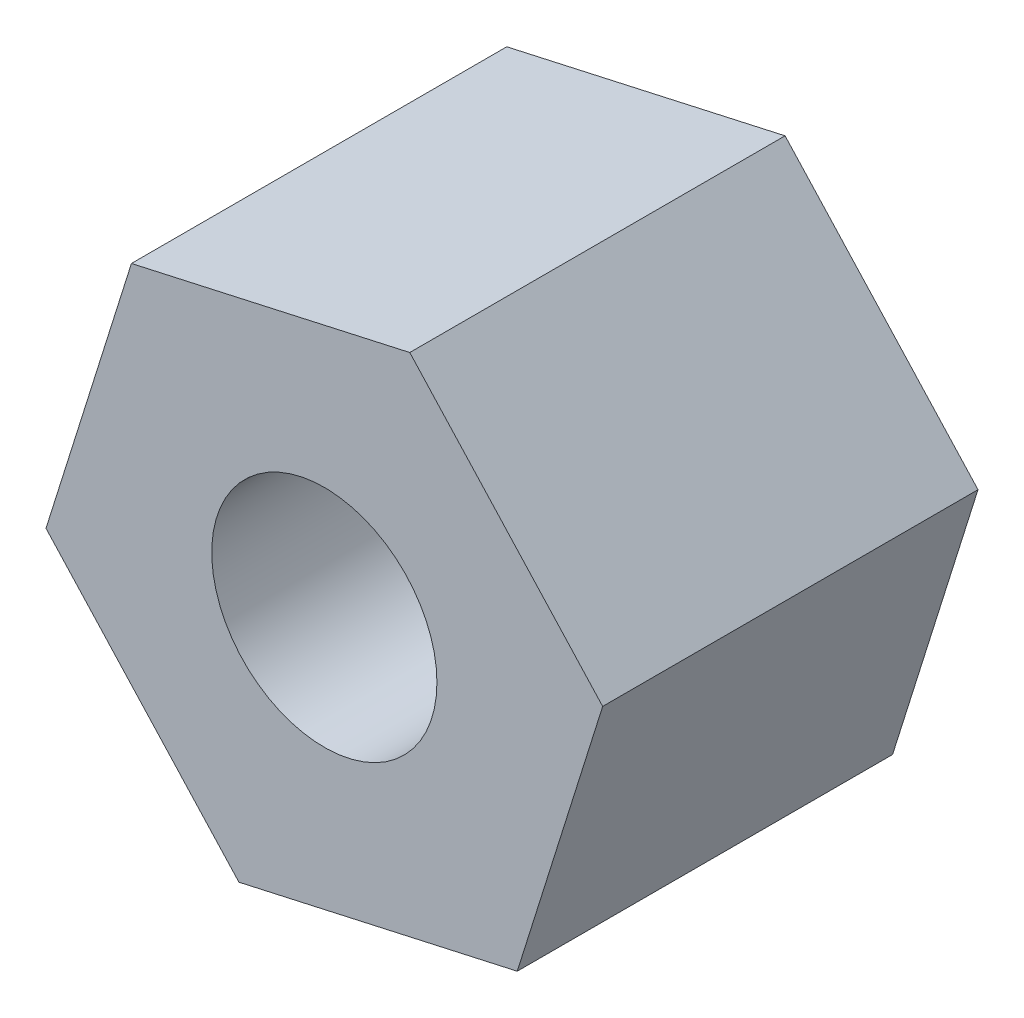
from build123d import *

# Parameters (mm, degrees)
SKETCH1_R           = 1.5
BOSS_EXTRUDE1_DEPTH = 5


with BuildPart() as part:
    # Sketch1 → Boss-Extrude1 (new body)
    with BuildSketch(Plane.XY):
        Polygon((1.138065646, 3.624491677), (-2.569869045, 2.797839599), (-3.707934691, -0.826652078), (-1.138065646, -3.624491677), (2.569869045, -2.797839599), (3.707934691, 0.826652078), align=None)
        Circle(SKETCH1_R, mode=Mode.SUBTRACT)
    extrude(amount=BOSS_EXTRUDE1_DEPTH)


solid = part.part
